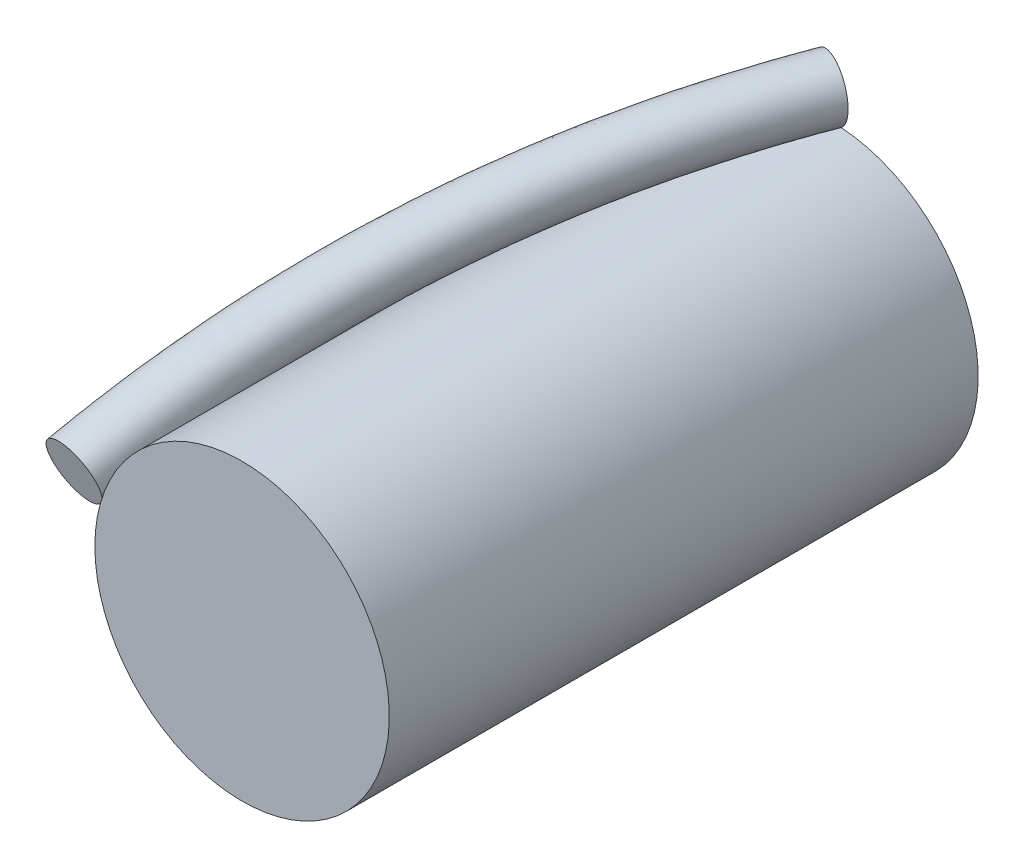
from build123d import *

# Parameters (mm, degrees)
SKIZZE1_W = 100
SKIZZE1_H = 25
SKIZZE4_R = 5


with BuildPart() as part:
    # Skizze1 → Rotation1 (revolve)
    with BuildSketch(Plane(origin=(0, 0, 0), x_dir=(0, 0, -1), z_dir=(1, 0, 0)), mode=Mode.PRIVATE) as rotation1_sk:
        with Locations((-50, 12.5)):
            Rectangle(SKIZZE1_W, SKIZZE1_H)
    revolve(rotation1_sk.sketch.rotate(Axis((0, 0, 0), (0, 0, 1)), 90), axis=Axis((0, 0, 0), (0, 0, 1)))  # turned: the seam where the file's is


with BuildPart() as body_2:
    # Austragung1: sweep along a curve in space
    with BuildLine() as austragung1_path:
        add(Edge.make_bspline(
            [(0, 30, 0), (-1.570595525, 30, 4.166134022), (-4.712463704, 29.752752169, 12.500247103), (-9.308687458, 28.649268716, 24.999934106), (-13.675845452, 26.840345901, 37.500016474), (-17.706220687, 24.370522034, 50), (-21.300617212, 21.300624951, 62.499983526), (-24.370531079, 17.706198775, 75.000065894), (-26.840317458, 13.675925363, 87.499752897), (-28.04635478, 10.764234939, 95.833865978), (-28.531695489, 9.270509831, 100)],
            knots=[0, 0, 0, 0, 0.125, 0.25, 0.375, 0.5, 0.625, 0.75, 0.875, 1, 1, 1, 1], degree=3))
    # Skizze4 → Austragung1 (sweep)
    with BuildSketch(Plane(origin=(0, 30, 0), x_dir=(0.93571522, 0, 0.352756327), z_dir=(-0.352756327, 0, 0.93571522))):
        Circle(SKIZZE4_R)
    sweep(path=austragung1_path.line, is_frenet=True)


solid = Compound([part.part, body_2.part])
